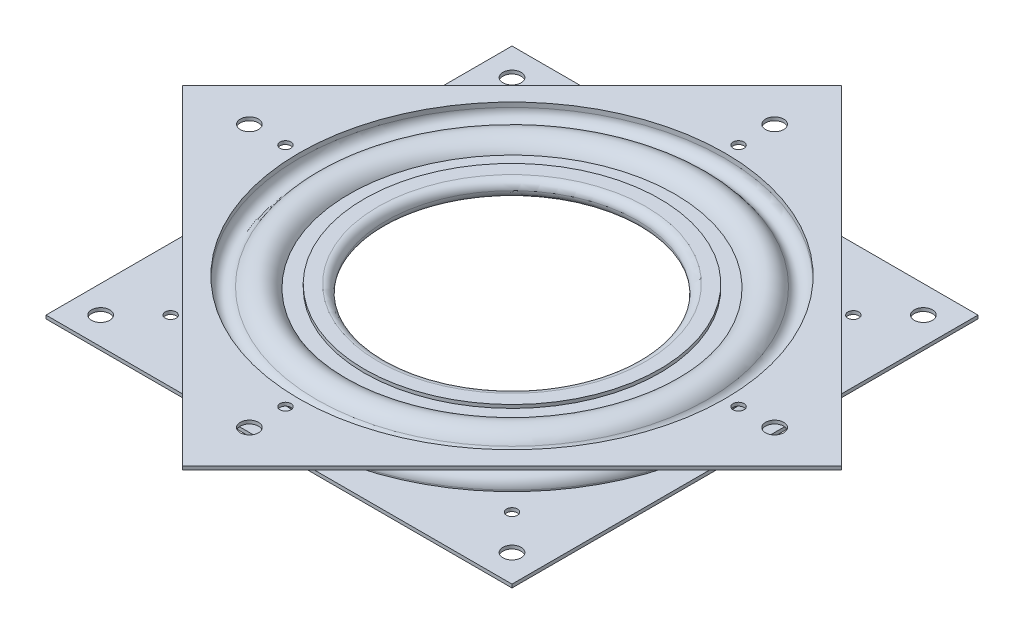
from build123d import *

# Parameters (mm, degrees)
SKETCH2_W                                 = 101.6
SKETCH2_H                                 = 101.6
SKETCH2_R                                 = 46.427290861
EXTRUDE1_DEPTH                            = 0.7366
SKETCH3_R                                 = 46.427290861
EXTRUDE2_DEPTH                            = 0.7366
CIRPATTERN1_COUNT                         = 4
SKETCH5_W                                 = 1.984375
SKETCH5_H                                 = 0.7366
F_5_32_0_156250_DIAMETER_HOLE1_AT_2_COUNT = 2
F_5_32_0_156250_DIAMETER_HOLE1_AT_2_PITCH = 89.6874
F_5_32_0_156250_DIAMETER_HOLE1_AT_3_COUNT = 2
F_5_32_0_156250_DIAMETER_HOLE1_AT_3_PITCH = 89.6874
F_5_32_0_156250_DIAMETER_HOLE1_AT_4_COUNT = 2
F_5_32_0_156250_DIAMETER_HOLE1_AT_4_PITCH = 126.837137454
SKETCH7_W                                 = 1.984375
SKETCH7_H                                 = 8.128
F_5_32_0_156250_DIAMETER_HOLE2_AT_2_COUNT = 2
F_5_32_0_156250_DIAMETER_HOLE2_AT_2_PITCH = 80.9752
F_5_32_0_156250_DIAMETER_HOLE2_AT_3_COUNT = 2
F_5_32_0_156250_DIAMETER_HOLE2_AT_3_PITCH = 114.516226056
F_5_32_0_156250_DIAMETER_HOLE2_AT_4_COUNT = 2
F_5_32_0_156250_DIAMETER_HOLE2_AT_4_PITCH = 80.9752
SKETCH9_W                                 = 1.190625
SKETCH9_H                                 = 0.7366
F_3_32_0_093750_DIAMETER_HOLE1_AT_2_COUNT = 2
F_3_32_0_093750_DIAMETER_HOLE1_AT_2_PITCH = 69.85
F_3_32_0_093750_DIAMETER_HOLE1_AT_3_COUNT = 2
F_3_32_0_093750_DIAMETER_HOLE1_AT_3_PITCH = 98.782817332
F_3_32_0_093750_DIAMETER_HOLE1_AT_4_COUNT = 2
F_3_32_0_093750_DIAMETER_HOLE1_AT_4_PITCH = 69.85
F_3_32_0_093750_DIAMETER_HOLE2_AT_2_COUNT = 2
F_3_32_0_093750_DIAMETER_HOLE2_AT_2_PITCH = 74.422
F_3_32_0_093750_DIAMETER_HOLE2_AT_3_COUNT = 2
F_3_32_0_093750_DIAMETER_HOLE2_AT_3_PITCH = 105.248601739
F_3_32_0_093750_DIAMETER_HOLE2_AT_4_COUNT = 2
F_3_32_0_093750_DIAMETER_HOLE2_AT_4_PITCH = 74.422


with BuildPart() as part:
    # Sketch1 → Revolve-Thin4 (revolve)
    with BuildSketch(Plane.XY):
        with BuildLine():
            Line((32.19552446, 1.778), (29.21, 1.778))
            ThreePointArc((29.21, 1.778), (27.432, 0), (29.21, -1.778))
            Line((29.21, -1.778), (35.18104892, -1.778))
            ThreePointArc((35.18104892, -1.778), (38.567175582, -4.788771381), (42.635527241, -2.794))
            ThreePointArc((42.635527241, -2.794), (44.921211161, -1.847238721), (46.427290861, -3.81))
            Line((46.427290861, -3.81), (46.427290861, -4.826))
            Line((46.427290861, -4.826), (50.8, -4.826))
            Line((50.8, -4.826), (50.8, -4.0894))
            Line((50.8, -4.0894), (47.163890861, -4.0894))
            Line((47.163890861, -4.0894), (47.163890861, -3.81))
            ThreePointArc((47.163890861, -3.81), (45.11185727, -1.135737757), (41.997612929, -2.4257))
            ThreePointArc((41.997612929, -2.4257), (38.390625346, -4.00937161), (35.800351285, -1.0414))
            Line((35.800351285, -1.0414), (29.21, -1.0414))
            ThreePointArc((29.21, -1.0414), (28.1686, 0), (29.21, 1.0414))
            Line((29.21, 1.0414), (32.19552446, 1.0414))
            Line((32.19552446, 1.0414), (32.19552446, 1.778))
        make_face()
    revolve(axis=Axis((0, 21.71272626, 0), (0, -1, 0)))

    # Sketch2 → Extrude1 (add)
    with BuildSketch(Plane.XZ.offset(4.826)):
        Rectangle(SKETCH2_W, SKETCH2_H)
        Circle(SKETCH2_R, mode=Mode.SUBTRACT)
    extrude(amount=-EXTRUDE1_DEPTH)

    # Sketch5 → 5_32 _0.156250_ Diameter Hole1 (revolve, cut)
    with BuildSketch(Plane(origin=(44.8437, -4.0894, -44.8437), x_dir=(0, 0, 1), z_dir=(1, 0, 0))):
        with Locations((0.9921875, 0.3683)):
            Rectangle(SKETCH5_W, SKETCH5_H)
    f_5_32_0_156250_diameter_hole1 = revolve(axis=Axis((44.8437, 2.2606, -44.8437), (0, -1, 0)), mode=Mode.SUBTRACT)

    # 5_32 _0.156250_ Diameter Hole1 at 2: 5_32 _0.156250_ Diameter Hole1 ×2
    with Locations(*[(0, 0, i * F_5_32_0_156250_DIAMETER_HOLE1_AT_2_PITCH) for i in range(1, F_5_32_0_156250_DIAMETER_HOLE1_AT_2_COUNT)]):
        add(f_5_32_0_156250_diameter_hole1, mode=Mode.SUBTRACT)

    # 5_32 _0.156250_ Diameter Hole1 at 3: 5_32 _0.156250_ Diameter Hole1 ×2
    with Locations(*[(-i * F_5_32_0_156250_DIAMETER_HOLE1_AT_3_PITCH, 0, 0) for i in range(1, F_5_32_0_156250_DIAMETER_HOLE1_AT_3_COUNT)]):
        add(f_5_32_0_156250_diameter_hole1, mode=Mode.SUBTRACT)

    # 5_32 _0.156250_ Diameter Hole1 at 4: 5_32 _0.156250_ Diameter Hole1 ×2
    with Locations(*[Vector(-0.707106781, 0, 0.707106781) * (i * F_5_32_0_156250_DIAMETER_HOLE1_AT_4_PITCH) for i in range(1, F_5_32_0_156250_DIAMETER_HOLE1_AT_4_COUNT)]):
        add(f_5_32_0_156250_diameter_hole1, mode=Mode.SUBTRACT)

    # Sketch11 → 3_32 _0.093750_ Diameter Hole2 (revolve, cut)
    with BuildSketch(Plane(origin=(37.211, -4.0894, 37.211), x_dir=(0, 0, 1), z_dir=(1, 0, 0))):
        Polygon((0, 0), (0, 26.115399675), (1.190625, 25.4), (1.190625, 0), align=None)
    f_3_32_0_093750_diameter_hole2 = revolve(axis=Axis((37.211, 2.2606, 37.211), (0, -1, 0)), mode=Mode.SUBTRACT)

    # 3_32 _0.093750_ Diameter Hole2 at 2: 3_32 _0.093750_ Diameter Hole2 ×2
    with Locations(*[(-i * F_3_32_0_093750_DIAMETER_HOLE2_AT_2_PITCH, 0, 0) for i in range(1, F_3_32_0_093750_DIAMETER_HOLE2_AT_2_COUNT)]):
        add(f_3_32_0_093750_diameter_hole2, mode=Mode.SUBTRACT)

    # 3_32 _0.093750_ Diameter Hole2 at 3: 3_32 _0.093750_ Diameter Hole2 ×2
    with Locations(*[Vector(-0.707106781, 0, -0.707106781) * (i * F_3_32_0_093750_DIAMETER_HOLE2_AT_3_PITCH) for i in range(1, F_3_32_0_093750_DIAMETER_HOLE2_AT_3_COUNT)]):
        add(f_3_32_0_093750_diameter_hole2, mode=Mode.SUBTRACT)

    # 3_32 _0.093750_ Diameter Hole2 at 4: 3_32 _0.093750_ Diameter Hole2 ×2
    with Locations(*[(0, 0, -i * F_3_32_0_093750_DIAMETER_HOLE2_AT_4_PITCH) for i in range(1, F_3_32_0_093750_DIAMETER_HOLE2_AT_4_COUNT)]):
        add(f_3_32_0_093750_diameter_hole2, mode=Mode.SUBTRACT)


with BuildPart() as body_2:
    # Sketch1_5 → Revolve-Thin5 (revolve)
    with BuildSketch(Plane.XY):
        with BuildLine():
            Line((29.21, 1.0414), (35.474043872, 1.0414))
            ThreePointArc((35.474043872, 1.0414), (38.986340067, 3.299931105), (42.635527241, 1.27))
            ThreePointArc((42.635527241, 1.27), (44.921211161, 0.323238721), (46.427290861, 2.286))
            Line((46.427290861, 2.286), (46.427290861, 3.302))
            Line((46.427290861, 3.302), (50.8, 3.302))
            Line((50.8, 3.302), (50.8, 2.5654))
            Line((50.8, 2.5654), (47.163890861, 2.5654))
            Line((47.163890861, 2.5654), (47.163890861, 2.286))
            ThreePointArc((47.163890861, 2.286), (45.11185727, -0.388262243), (41.997612929, 0.9017))
            ThreePointArc((41.997612929, 0.9017), (38.788408911, 2.54923464), (35.964249927, 0.3048))
            Line((35.964249927, 0.3048), (29.21, 0.3048))
            Line((29.21, 0.3048), (29.21, 1.0414))
        make_face()
    revolve(axis=Axis((0, 21.71272626, 0), (0, -1, 0)))

    # Sketch3 → Extrude2 (add)
    with BuildSketch(Plane(origin=(0, 3.302, 0), x_dir=(-1, 0, 0), z_dir=(0, 1, 0))):
        Polygon((0, -71.842048969), (71.842048969, 0), (0, 71.842048969), (-71.842048969, 0), align=None)
        Circle(SKETCH3_R, mode=Mode.SUBTRACT)
    extrude(amount=-EXTRUDE2_DEPTH)

    # Sketch7 → 5_32 _0.156250_ Diameter Hole2 (revolve, cut)
    with BuildSketch(Plane(origin=(57.258113028, 3.302, 0), x_dir=(0, 0, 1), z_dir=(1, 0, 0))):
        with Locations((0.9921875, 4.064)):
            Rectangle(SKETCH7_W, SKETCH7_H)
    f_5_32_0_156250_diameter_hole2 = revolve(axis=Axis((57.258113028, 9.652, 0), (0, -1, 0)), mode=Mode.SUBTRACT)

    # 5_32 _0.156250_ Diameter Hole2 at 2: 5_32 _0.156250_ Diameter Hole2 ×2
    with Locations(*[Vector(-0.707106781, 0, -0.707106781) * (i * F_5_32_0_156250_DIAMETER_HOLE2_AT_2_PITCH) for i in range(1, F_5_32_0_156250_DIAMETER_HOLE2_AT_2_COUNT)]):
        add(f_5_32_0_156250_diameter_hole2, mode=Mode.SUBTRACT)

    # 5_32 _0.156250_ Diameter Hole2 at 3: 5_32 _0.156250_ Diameter Hole2 ×2
    with Locations(*[(-i * F_5_32_0_156250_DIAMETER_HOLE2_AT_3_PITCH, 0, 0) for i in range(1, F_5_32_0_156250_DIAMETER_HOLE2_AT_3_COUNT)]):
        add(f_5_32_0_156250_diameter_hole2, mode=Mode.SUBTRACT)

    # 5_32 _0.156250_ Diameter Hole2 at 4: 5_32 _0.156250_ Diameter Hole2 ×2
    with Locations(*[Vector(-0.707106781, 0, 0.707106781) * (i * F_5_32_0_156250_DIAMETER_HOLE2_AT_4_PITCH) for i in range(1, F_5_32_0_156250_DIAMETER_HOLE2_AT_4_COUNT)]):
        add(f_5_32_0_156250_diameter_hole2, mode=Mode.SUBTRACT)

    # Sketch9 → 3_32 _0.093750_ Diameter Hole1 (revolve, cut)
    with BuildSketch(Plane(origin=(0, 3.302, -49.391408666), x_dir=(0, 0, 1), z_dir=(1, 0, 0))):
        with Locations((0.5953125, 0.3683)):
            Rectangle(SKETCH9_W, SKETCH9_H)
    f_3_32_0_093750_diameter_hole1 = revolve(axis=Axis((0, 9.652, -49.391408666), (0, -1, 0)), mode=Mode.SUBTRACT)

    # 3_32 _0.093750_ Diameter Hole1 at 2: 3_32 _0.093750_ Diameter Hole1 ×2
    with Locations(*[Vector(0.707106781, 0, 0.707106781) * (i * F_3_32_0_093750_DIAMETER_HOLE1_AT_2_PITCH) for i in range(1, F_3_32_0_093750_DIAMETER_HOLE1_AT_2_COUNT)]):
        add(f_3_32_0_093750_diameter_hole1, mode=Mode.SUBTRACT)

    # 3_32 _0.093750_ Diameter Hole1 at 3: 3_32 _0.093750_ Diameter Hole1 ×2
    with Locations(*[(0, 0, i * F_3_32_0_093750_DIAMETER_HOLE1_AT_3_PITCH) for i in range(1, F_3_32_0_093750_DIAMETER_HOLE1_AT_3_COUNT)]):
        add(f_3_32_0_093750_diameter_hole1, mode=Mode.SUBTRACT)

    # 3_32 _0.093750_ Diameter Hole1 at 4: 3_32 _0.093750_ Diameter Hole1 ×2
    with Locations(*[Vector(-0.707106781, 0, 0.707106781) * (i * F_3_32_0_093750_DIAMETER_HOLE1_AT_4_PITCH) for i in range(1, F_3_32_0_093750_DIAMETER_HOLE1_AT_4_COUNT)]):
        add(f_3_32_0_093750_diameter_hole1, mode=Mode.SUBTRACT)


with BuildPart() as body_3:
    # Sketch4 → Revolve1 (revolve)
    with BuildSketch(Plane.XY):
        with BuildLine():
            Line((39.116, 2.5146), (39.116, -4.0386))
            ThreePointArc((39.116, -4.0386), (42.3926, -0.762), (39.116, 2.5146))
        make_face()
    revolve(axis=Axis((39.116, 2.837450101, 0), (0, -1, 0)))


with BuildPart() as cirpattern1_1:
    # CirPattern1: pattern copy
    add(body_3.part.rotate(Axis((0, 0, 0), (0, 1, 0)), 1 * 360 / CIRPATTERN1_COUNT))


with BuildPart() as cirpattern1_2:
    # CirPattern1: pattern copy
    add(body_3.part.rotate(Axis((0, 0, 0), (0, 1, 0)), 2 * 360 / CIRPATTERN1_COUNT))


with BuildPart() as cirpattern1_3:
    # CirPattern1: pattern copy
    add(body_3.part.rotate(Axis((0, 0, 0), (0, 1, 0)), 3 * 360 / CIRPATTERN1_COUNT))


solid = Compound([part.part, body_2.part, body_3.part, cirpattern1_1.part, cirpattern1_2.part, cirpattern1_3.part])
